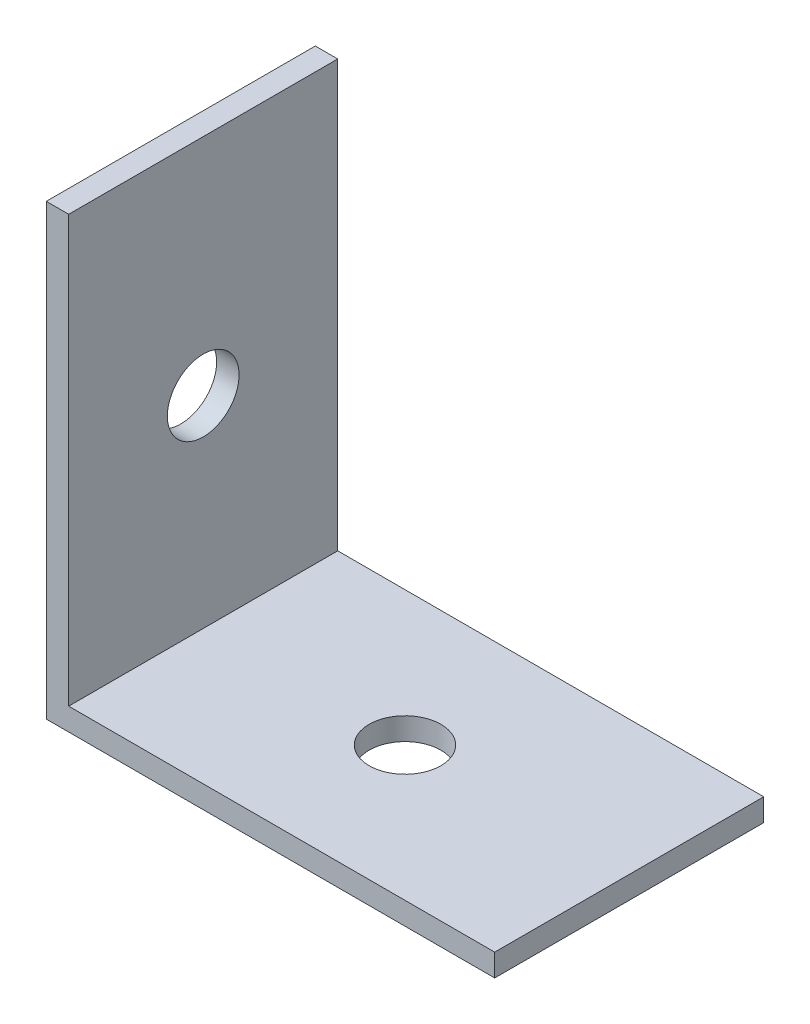
from build123d import *

# Parameters (mm, degrees)
BOSS_EXTRUDE1_DEPTH = 12
SKETCH2_R           = 1.6
CUT_EXTRUDE1_DEPTH  = 21
SKETCH3_R           = 1.6
CUT_EXTRUDE2_DEPTH  = 21


with BuildPart() as part:
    # Sketch1 → Boss-Extrude1 (new body)
    with BuildSketch(Plane.XY):
        Polygon((0, 0), (20, 0), (20, 1), (1, 1), (1, 20), (0, 20), align=None)
    extrude(amount=BOSS_EXTRUDE1_DEPTH)

    # Sketch2 → Cut-Extrude1 (cut, through all)
    with BuildSketch(Plane.XZ):
        with Locations((10, 6)):
            Circle(SKETCH2_R)
    extrude(amount=-CUT_EXTRUDE1_DEPTH, mode=Mode.SUBTRACT)

    # Sketch3 → Cut-Extrude2 (cut, through all)
    with BuildSketch(Plane.ZY):
        with Locations((6, 10)):
            Circle(SKETCH3_R)
    extrude(amount=-CUT_EXTRUDE2_DEPTH, mode=Mode.SUBTRACT)


solid = part.part
